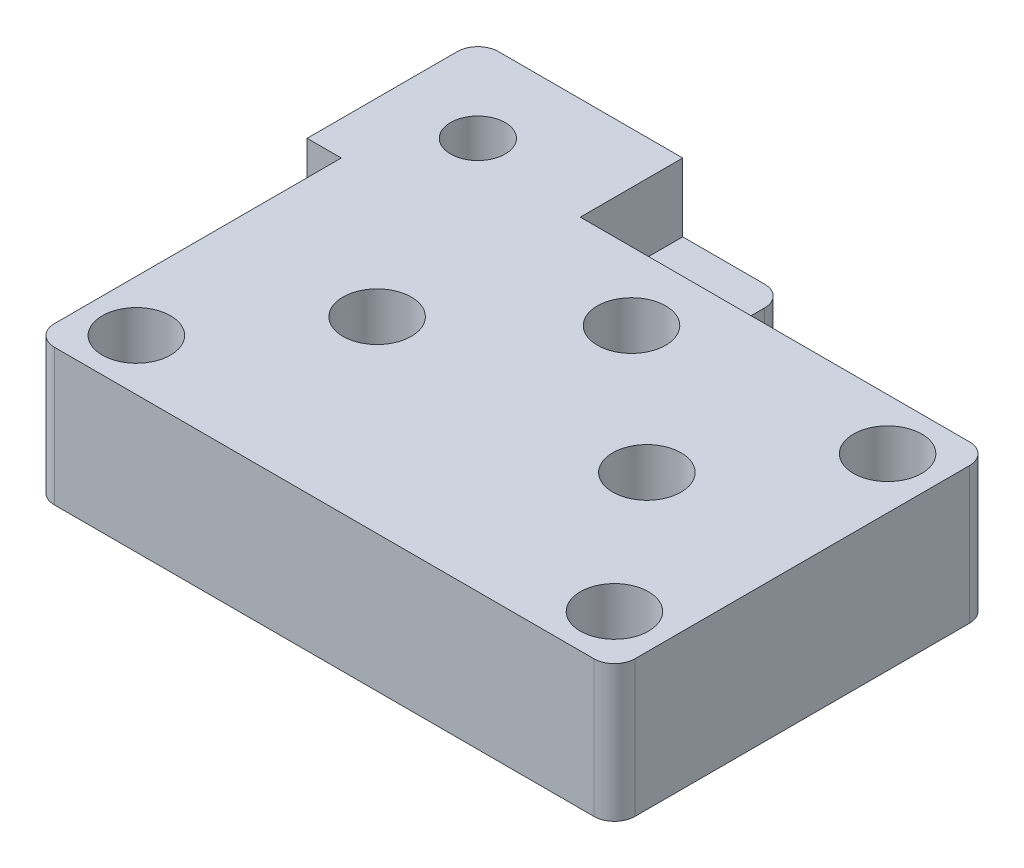
from build123d import *

# Parameters (mm, degrees)
SALIENTE_EXTRUIR1_DEPTH = 20
CROQUIS2_R              = 2.5
CROQUIS2_R_2            = 5
CORTAR_EXTRUIR1_DEPTH   = 20
CROQUIS3_R              = 4
CROQUIS3_R_2            = 5
CORTAR_EXTRUIR2_DEPTH   = 20
CORTAR_EXTRUIR3_DEPTH   = 7.5
CROQUIS5_R              = 5
CROQUIS5_W              = 15
CROQUIS5_H              = 15
CORTAR_EXTRUIR4_DEPTH   = 10
REDONDEO1_R             = 3


with BuildPart() as part:
    # Croquis1 → Saliente-Extruir1 (new body)
    with BuildSketch(Plane(origin=(0, 0, 0), x_dir=(1, 0, 0), z_dir=(0, 1, 0))):
        Polygon((-2.5, 27.5), (-2.5, 42.5), (-47.5, 42.5), (-47.5, 17.5), (-42.5, 17.5), (-42.5, -27.5), (42.5, -27.5), (42.5, 27.5), align=None)
    extrude(amount=SALIENTE_EXTRUIR1_DEPTH)

    # Croquis2 → Cortar-Extruir1 (cut)
    with BuildSketch(Plane(origin=(0, 20, 0), x_dir=(1, 0, 0), z_dir=(0, 1, 0))):
        with Locations((35, 20)):
            Circle(CROQUIS2_R)
        with Locations((35, -20)):
            Circle(CROQUIS2_R)
        with Locations((-35, -20)):
            Circle(CROQUIS2_R)
        with Locations((-10, 35)):
            Circle(CROQUIS2_R)
        with Locations((-19.75, 0)):
            Circle(CROQUIS2_R_2)
        with Locations((19.75, 0)):
            Circle(CROQUIS2_R_2)
    extrude(amount=-CORTAR_EXTRUIR1_DEPTH, mode=Mode.SUBTRACT)

    # Croquis3 → Cortar-Extruir2 (cut)
    with BuildSketch(Plane(origin=(0, 20, 0), x_dir=(1, 0, 0), z_dir=(0, 1, 0))):
        with Locations((-35, 30)):
            Circle(CROQUIS3_R)
        with Locations((0, 17.5)):
            Circle(CROQUIS3_R_2)
    extrude(amount=-CORTAR_EXTRUIR2_DEPTH, mode=Mode.SUBTRACT)

    # Croquis4 → Cortar-Extruir3 (cut)
    with BuildSketch(Plane.XZ):
        Polygon((19.75, -9.814954576), (28.25, -4.907477288), (28.25, 4.907477288), (19.75, 9.814954576), (11.25, 4.907477288), (11.25, -4.907477288), align=None)
        Polygon((-19.655862416, -9.814503118), (-11.203322183, -4.82572602), (-11.297459766, 4.988777098), (-19.844137584, 9.814503118), (-28.296677817, 4.82572602), (-28.202540234, -4.988777098), align=None)
        Polygon((-35, -39.814954576), (-26.5, -34.907477288), (-26.5, -25.092522712), (-35, -20.185045424), (-43.5, -25.092522712), (-43.5, -34.907477288), align=None)
    extrude(amount=-CORTAR_EXTRUIR3_DEPTH, mode=Mode.SUBTRACT)

    # Croquis5 → Cortar-Extruir4 (cut)
    with BuildSketch(Plane(origin=(0, 20, 0), x_dir=(1, 0, 0), z_dir=(0, 1, 0))):
        with Locations((-35, -20)):
            Circle(CROQUIS5_R)
        with Locations((35, -20)):
            Circle(CROQUIS5_R)
        with Locations((35, 20)):
            Circle(CROQUIS5_R)
        with Locations((-10, 35)):
            Rectangle(CROQUIS5_W, CROQUIS5_H)
    extrude(amount=-CORTAR_EXTRUIR4_DEPTH, mode=Mode.SUBTRACT)

    # Redondeo1
    redondeo1_edges = [part.edges().sort_by_distance(p)[0] for p in [
        (-2.5, 5, -42.5),
        (42.5, 10, 27.5),
        (-42.5, 10, 27.5),
        (-47.5, 10, -42.5),
        (42.5, 10, -27.5),
    ]]
    fillet(redondeo1_edges, radius=REDONDEO1_R)


solid = part.part
